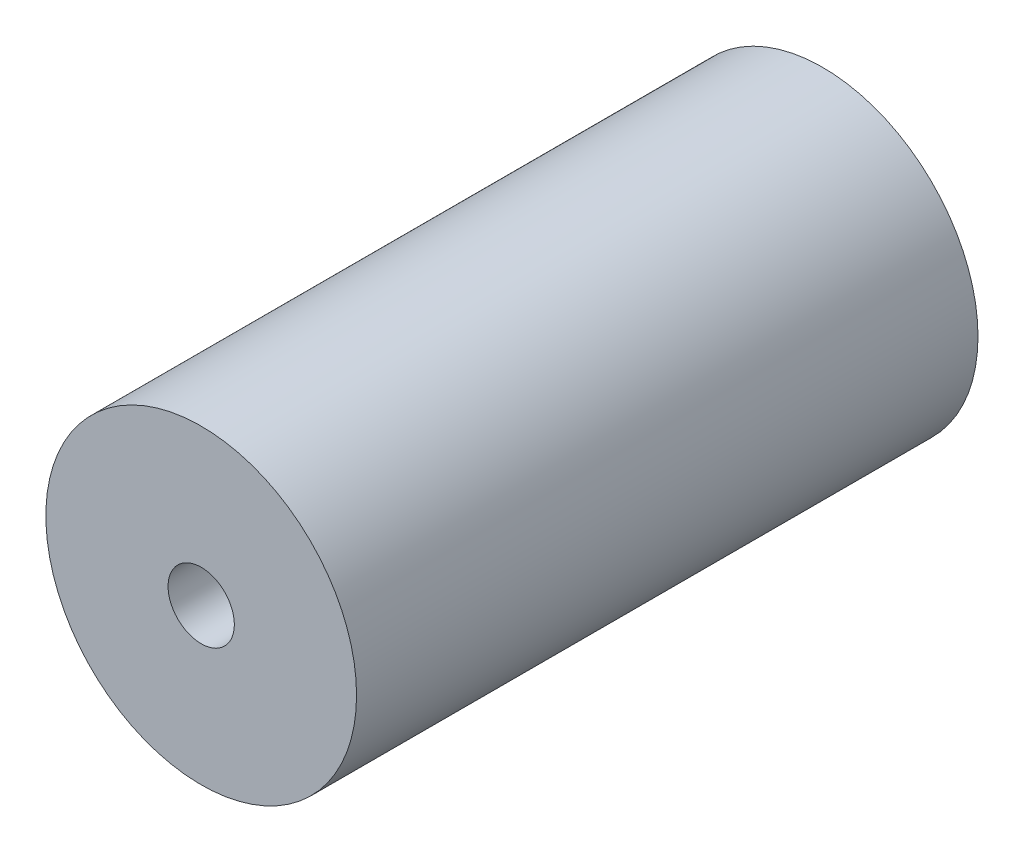
from build123d import *

# Parameters (mm, degrees)
SKETCH_1_R          = 7.5
EXTRUDE_1_DEPTH     = 30
SKETCH_2_R          = 1.6
CUT_EXTRUDE_1_DEPTH = 31


with BuildPart() as part:
    # ｽｹｯﾁ1 → ﾎﾞｽ - 押し出し1 (new body)
    with BuildSketch(Plane.XY):
        Circle(SKETCH_1_R)
    extrude(amount=EXTRUDE_1_DEPTH)

    # ｽｹｯﾁ2 → ｶｯﾄ - 押し出し1 (cut, through all)
    with BuildSketch(Plane.XY.offset(30)):
        Circle(SKETCH_2_R)
    extrude(amount=-CUT_EXTRUDE_1_DEPTH, mode=Mode.SUBTRACT)


solid = part.part
